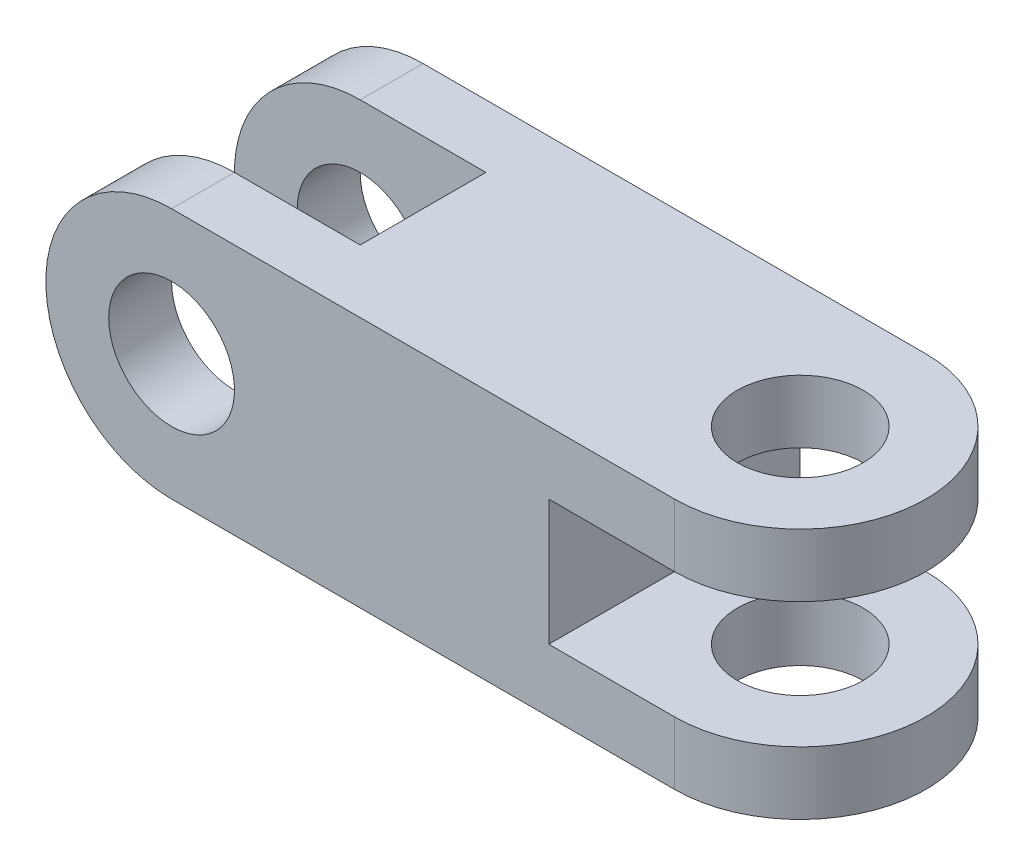
from build123d import *

# Parameters (mm, degrees)
ESQUISSE1_R        = 5
BOSS_EXTRU_1_DEPTH = 20
ESQUISSE2_R        = 5
BOSS_EXTRU_2_DEPTH = 20


with BuildPart() as part:
    # Esquisse1 → Boss.-Extru.1 (new body)
    with BuildSketch(Plane.XY):
        with BuildLine():
            Line((0, 0), (50, 0))
            Line((50, 0), (50, 5))
            Line((50, 5), (30, 5))
            Line((30, 5), (30, 15))
            Line((30, 15), (50, 15))
            Line((50, 15), (50, 20))
            Line((50, 20), (0, 20))
            ThreePointArc((0, 20), (-10, 10), (0, 0))
        make_face()
        with Locations((0, 10)):
            Circle(ESQUISSE1_R, mode=Mode.SUBTRACT)
    extrude(amount=BOSS_EXTRU_1_DEPTH)


with BuildPart() as body_2:
    # Esquisse2 → Boss.-Extru.2 (new body)
    with BuildSketch(Plane(origin=(0, 0, 0), x_dir=(1, 0, 0), z_dir=(0, 1, 0))):
        with BuildLine():
            Line((40, 0), (-10, 0))
            Line((-10, 0), (-10, -5))
            Line((-10, -5), (10, -5))
            Line((10, -5), (10, -15))
            Line((10, -15), (-10, -15))
            Line((-10, -15), (-10, -20))
            Line((-10, -20), (40, -20))
            ThreePointArc((40, -20), (50, -10), (40, 0))
        make_face()
        with Locations((40, -10)):
            Circle(ESQUISSE2_R, mode=Mode.SUBTRACT)
    extrude(amount=BOSS_EXTRU_2_DEPTH)

    # Combiner1: intersect part
    add(part.part, mode=Mode.INTERSECT)


solid = body_2.part
